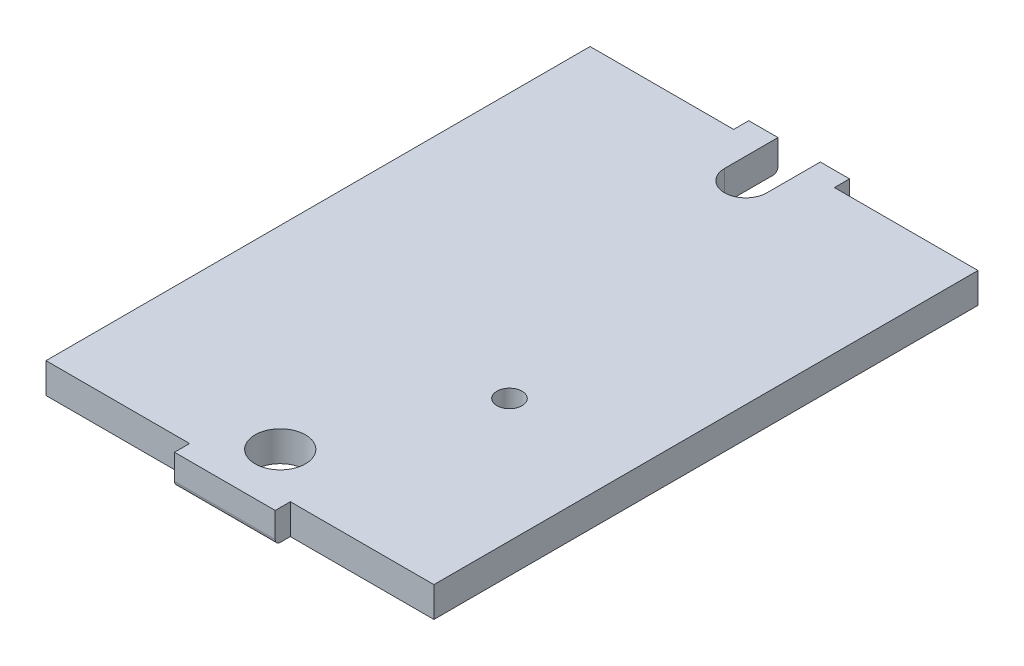
from build123d import *

# Parameters (mm, degrees)
BOSS_EXTRUDE1_DEPTH = 3
FILLET1_R           = 0.5
SKETCH2_R           = 2.5
CUT_EXTRUDE1_DEPTH  = 4
CUT_EXTRUDE2_DEPTH  = 4
SKETCH4_R           = 1.25
CUT_EXTRUDE3_DEPTH  = 4
CHAMFER1_SIZE       = 0.5


with BuildPart() as part:
    # Sketch1 → Boss-Extrude1 (new body)
    with BuildSketch(Plane(origin=(0, 0, 0), x_dir=(1, 0, 0), z_dir=(0, 1, 0))):
        Polygon((-19.25, 27), (-19.25, -27), (-5, -27), (-5, -28.5), (5, -28.5), (5, -27), (19.25, -27), (19.25, 27), (5, 27), (5, 28.5), (-5, 28.5), (-5, 27), align=None)
    extrude(amount=BOSS_EXTRUDE1_DEPTH)

    # Fillet1
    fillet1_edges = [part.edges().sort_by_distance(p)[0] for p in [
        (0, 0, 28.5),
        (0, 0, -28.5),
    ]]
    fillet(fillet1_edges, radius=FILLET1_R)

    # Sketch2 → Cut-Extrude1 (cut, through all)
    with BuildSketch(Plane(origin=(0, 3, 0), x_dir=(1, 0, 0), z_dir=(0, 1, 0))):
        with Locations((0, -23)):
            Circle(SKETCH2_R)
    extrude(amount=-CUT_EXTRUDE1_DEPTH, mode=Mode.SUBTRACT)

    # Sketch3 → Cut-Extrude2 (cut, through all)
    with BuildSketch(Plane(origin=(0, 3, 0), x_dir=(1, 0, 0), z_dir=(0, 1, 0))):
        with BuildLine():
            Line((-2.1, 28.5), (2.1, 28.5))
            Line((2.1, 28.5), (2.1, 23.2))
            ThreePointArc((2.1, 23.2), (0, 21.1), (-2.1, 23.2))
            Line((-2.1, 23.2), (-2.1, 28.5))
        make_face()
    extrude(amount=-CUT_EXTRUDE2_DEPTH, mode=Mode.SUBTRACT)

    # Sketch4 → Cut-Extrude3 (cut, through all)
    with BuildSketch(Plane(origin=(0, 3, 0), x_dir=(1, 0, 0), z_dir=(0, 1, 0))):
        with Locations((7, -7.25)):
            Circle(SKETCH4_R)
    extrude(amount=-CUT_EXTRUDE3_DEPTH, mode=Mode.SUBTRACT)

    # Chamfer1
    chamfer1_edges = [part.edges().sort_by_distance(p)[0] for p in [
        (5.75, 0, 7.25),
    ]]
    chamfer(chamfer1_edges, length=CHAMFER1_SIZE)


solid = part.part
